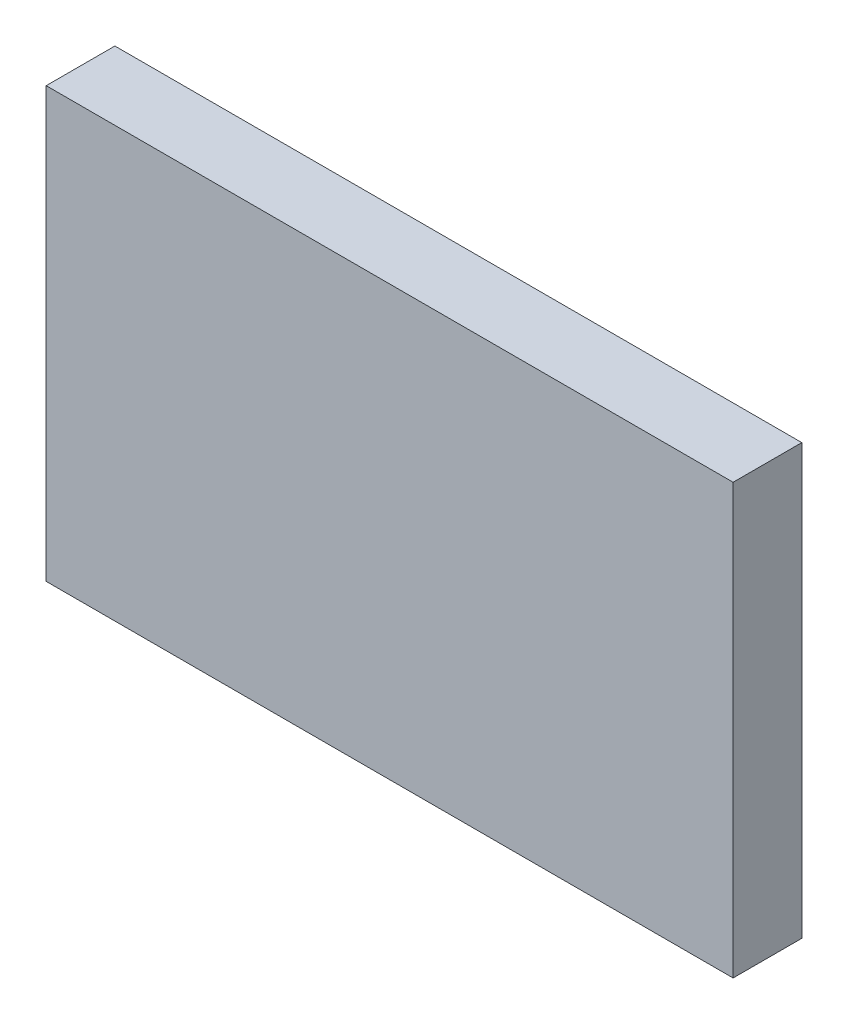
from build123d import *

# Parameters (mm, degrees)
SKETCH_1_W      = 80
SKETCH_1_H      = 50
EXTRUDE_1_DEPTH = 8


with BuildPart() as part:
    # 草图1 → 凸台-拉伸1 (new body)
    with BuildSketch(Plane.XY):
        Rectangle(SKETCH_1_W, SKETCH_1_H)
    extrude(amount=EXTRUDE_1_DEPTH)


solid = part.part
